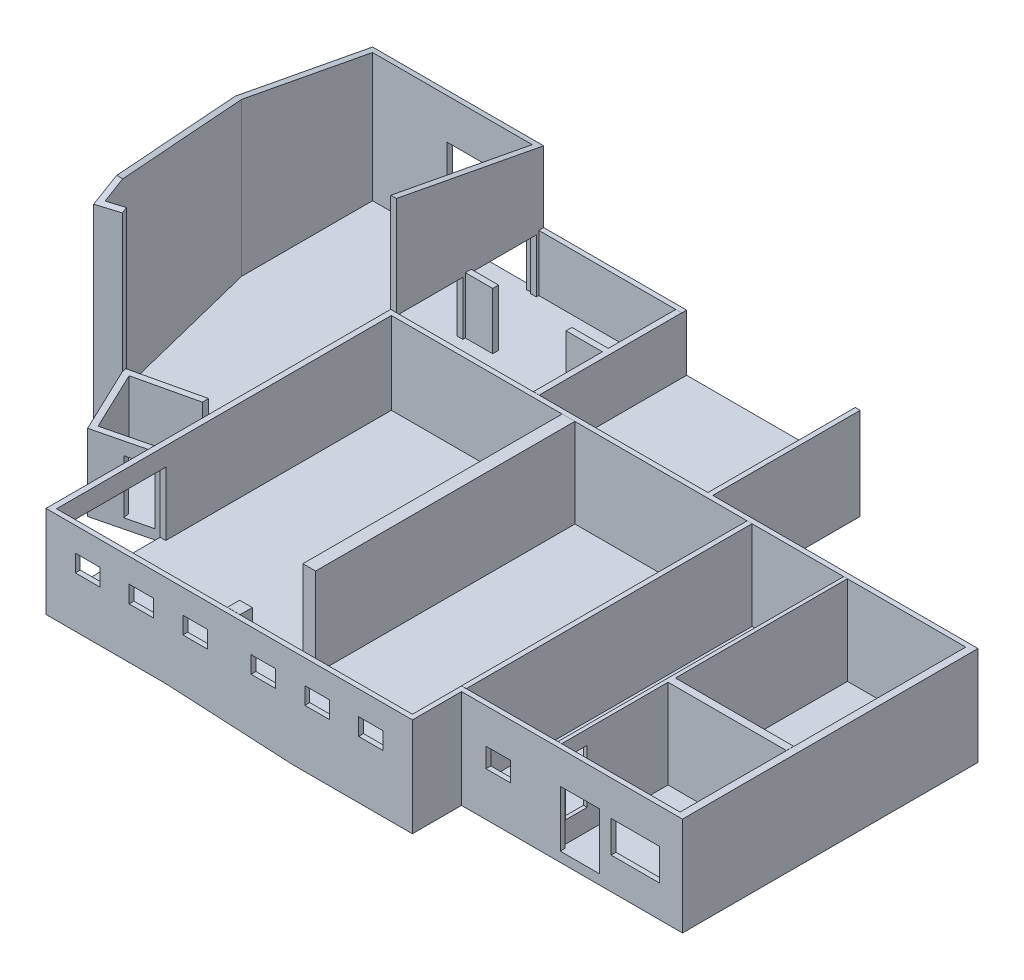
from build123d import *

# Parameters (mm, degrees)
AUFSATZ_LINEAR_AUSTRAGEN4_DEPTH                = 250
SKIZZE5_W                                      = 12750
SKIZZE5_H                                      = 5830
AUFSATZ_LINEAR_AUSTRAGEN5_DEPTH                = 3635
SKIZZE6_W                                      = 200
SKIZZE6_H                                      = 11690
SKIZZE6_W_2                                    = 520
SKIZZE6_H_2                                    = 10610
SKIZZE6_H_3                                    = 500
SKIZZE6_W_3                                    = 1120
SKIZZE6_H_4                                    = 240
AUFSATZ_LINEAR_AUSTRAGEN6_DEPTH                = 3640
SCHNITT_LINEAR_AUSTRAGEN1_REACH                = 30348.456
SKIZZE7_W                                      = 1980
SKIZZE7_H                                      = 1300
SKIZZE7_W_2                                    = 1600
SKIZZE7_H_2                                    = 2300
SKIZZE7_W_3                                    = 1000
SKIZZE7_H_3                                    = 800
SCHNITT_LINEAR_AUSTRAGEN2_REACH                = 27879.968
SKIZZE8_W                                      = 890
SKIZZE8_H                                      = 2200
SCHNITT_LINEAR_AUSTRAGEN3_REACH                = 31589.813
SKIZZE9_W                                      = 3870
SKIZZE9_H                                      = 2600
SKIZZE9_W_2                                    = 2565
SKIZZE9_H_2                                    = 2200
AUFSATZ_LINEAR_AUSTRAGEN7_DEPTH                = 3000
SKIZZE11_W                                     = 6990
SKIZZE11_H                                     = 13700
AUFSATZ_LINEAR_AUSTRAGEN8_DEPTH                = 275
SKIZZE12_W                                     = 12750
SKIZZE12_H                                     = 5830
AUFSATZ_LINEAR_AUSTRAGEN9_DEPTH                = 1325
AUFSATZ_LINEAR_AUSTRAGEN10_REACH               = 31462.736
SCHNITT_LINEAR_AUSTRAGEN4_DEPTH                = 3090
AUFSATZ_LINEAR_AUSTRAGEN12_DEPTH               = 8000
AUFSATZ_LINEAR_AUSTRAGEN13_DEPTH               = 1575
SCHNITT_LINEAR_AUSTRAGEN8_DEPTH                = 37827.06409607
SCHNITT_LINEAR_AUSTRAGEN8_DEPTH_BACK           = 37827.06409607
AUFSATZ_LINEAR_AUSTRAGEN14_REACH               = 31776.265
SKIZZE21_W                                     = 230
SKIZZE21_H                                     = 6030
SCHNITT_LINEAR_AUSTRAGEN9_DEPTH                = 1200
SCHNITT_LINEAR_AUSTRAGEN10_DEPTH               = 1050
SKIZZE24_W                                     = 1040
SKIZZE24_H                                     = 2200
SCHNITT_LINEAR_AUSTRAGEN11_DEPTH               = 300
SCHNITT_LINEAR_AUSTRAGEN12_REACH               = 32636.812
SKIZZE25_W                                     = 1000
SKIZZE25_H                                     = 700
SCHNITT_LINEAR_AUSTRAGEN13_REACH               = 32513.828
SKIZZE26_W                                     = 6900
SKIZZE26_H                                     = 3817.744695197
SCHNITT_LINEAR_AUSTRAGEN14_REACH               = 32489.323
SKIZZE27_W                                     = 3250
SKIZZE27_H                                     = 3600
AUFSATZ_LINEAR_AUSTRAGEN15_DEPTH               = 150
SCHNITT_LINEAR_AUSTRAGEN15_DEPTH               = 275
SCHNITT_LINEAR_AUSTRAGEN16_DEPTH               = 1050
SCHNITT_LINEAR_AUSTRAGEN17_REACH               = 33078.845
SCHNITT_LINEAR_AUSTRAGEN17_OFFSET_FROM_SURFACE = 400
SKIZZE31_W                                     = 5235
SKIZZE31_H                                     = 3290
SCHNITT_LINEAR_AUSTRAGEN18_DEPTH               = 1515


with BuildPart() as part:
    # Skizze1 → Aufsatz-Linear austragen4 (new body)
    with BuildSketch(Plane(origin=(0, 0, 0), x_dir=(1, 0, 0), z_dir=(0, 1, 0))):
        Polygon((14990, -18120), (14990, -20130), (0, -20130), (0, 0), (13180, 0), (13180, -6030), (24030, -6030), (24030, -18120), align=None)
    extrude(amount=AUFSATZ_LINEAR_AUSTRAGEN4_DEPTH)

    # Skizze5 → Aufsatz-Linear austragen5 (add)
    with BuildSketch(Plane(origin=(0, 250, 0), x_dir=(1, 0, 0), z_dir=(0, 1, 0))):
        Polygon((0, -20130), (14990, -20130), (14990, -18120), (24030, -18120), (24030, -6030), (13180, -6030), (13180, 0), (0, 0), align=None)
        Polygon((23730, -6230), (23730, -17920), (14790, -17920), (14790, -19930), (230, -19930), (230, -6230), align=None, mode=Mode.SUBTRACT)
        with Locations((6605, -3115)):
            Rectangle(SKIZZE5_W, SKIZZE5_H, mode=Mode.SUBTRACT)
    extrude(amount=AUFSATZ_LINEAR_AUSTRAGEN5_DEPTH)

    # Skizze6 → Aufsatz-Linear austragen6 (add)
    with BuildSketch(Plane(origin=(0, 250, 0), x_dir=(1, 0, 0), z_dir=(0, 1, 0))):
        Polygon((18890, -17920), (18890, -13570), (23730, -13570), (23730, -13270), (18890, -13270), (18890, -6230), (18740, -6230), (18740, -17920), align=None)
        with Locations((14890, -12075)):
            Rectangle(SKIZZE6_W, SKIZZE6_H)
        Polygon((5840, -200), (6080, -200), (6080, -6030), (5840, -6030), (5840, -3205), (4350, -3205), (4350, -2965), (5840, -2965), align=None)
        with Locations((7480, -11535)):
            Rectangle(SKIZZE6_W_2, SKIZZE6_H_2)
        with Locations((7480, -19680)):
            Rectangle(SKIZZE6_W_2, SKIZZE6_H_3)
        with Locations((790, -3085)):
            Rectangle(SKIZZE6_W_3, SKIZZE6_H_4)
    extrude(amount=AUFSATZ_LINEAR_AUSTRAGEN6_DEPTH)

    # Skizze7 → Schnitt-Linear austragen1 (cut, up to next)
    with BuildSketch(Plane.XY.offset(18120), mode=Mode.PRIVATE) as schnitt_linear_austragen1_sk1:
        with Locations((22100, 1800)):
            Rectangle(SKIZZE7_W, SKIZZE7_H)
    schnitt_linear_austragen1_tool1 = extrude(schnitt_linear_austragen1_sk1.sketch, amount=-SCHNITT_LINEAR_AUSTRAGEN1_REACH, mode=Mode.PRIVATE) & part.part
    # Skizze7 → Schnitt-Linear austragen1 (cut, up to next)
    with BuildSketch(Plane.XY.offset(18120), mode=Mode.PRIVATE) as schnitt_linear_austragen1_sk2:
        with Locations((19830, 1400)):
            Rectangle(SKIZZE7_W_2, SKIZZE7_H_2)
    schnitt_linear_austragen1_tool2 = extrude(schnitt_linear_austragen1_sk2.sketch, amount=-SCHNITT_LINEAR_AUSTRAGEN1_REACH, mode=Mode.PRIVATE) & part.part
    # Skizze7 → Schnitt-Linear austragen1 (cut, up to next)
    with BuildSketch(Plane.XY.offset(18120), mode=Mode.PRIVATE) as schnitt_linear_austragen1_sk3:
        with Locations((16490, 2050)):
            Rectangle(SKIZZE7_W_3, SKIZZE7_H_3)
    schnitt_linear_austragen1_tool3 = extrude(schnitt_linear_austragen1_sk3.sketch, amount=-SCHNITT_LINEAR_AUSTRAGEN1_REACH, mode=Mode.PRIVATE) & part.part
    add(schnitt_linear_austragen1_tool1.solids().sort_by_distance((22100, 1800, 18120))[0], mode=Mode.SUBTRACT)
    add(schnitt_linear_austragen1_tool2.solids().sort_by_distance((19830, 1400, 18120))[0], mode=Mode.SUBTRACT)
    add(schnitt_linear_austragen1_tool3.solids().sort_by_distance((16490, 2050, 18120))[0], mode=Mode.SUBTRACT)

    # Skizze8 → Schnitt-Linear austragen2 (cut, up to next)
    with BuildSketch(Plane(origin=(18890, 0, 0), x_dir=(0, 0, -1), z_dir=(1, 0, 0)), mode=Mode.PRIVATE) as schnitt_linear_austragen2_sk1:
        with Locations((-17325, 2210)):
            Rectangle(SKIZZE8_W, SKIZZE8_H)
    schnitt_linear_austragen2_tool1 = extrude(schnitt_linear_austragen2_sk1.sketch, amount=-SCHNITT_LINEAR_AUSTRAGEN2_REACH, mode=Mode.PRIVATE) & part.part
    add(schnitt_linear_austragen2_tool1.solids().sort_by_distance((18890, 2210, 17325))[0], mode=Mode.SUBTRACT)

    # Skizze9 → Schnitt-Linear austragen3 (cut, up to next)
    with BuildSketch(Plane.ZY, mode=Mode.PRIVATE) as schnitt_linear_austragen3_sk1:
        with Locations((17395, 1825)):
            Rectangle(SKIZZE9_W, SKIZZE9_H)
    schnitt_linear_austragen3_tool1 = extrude(schnitt_linear_austragen3_sk1.sketch, amount=-SCHNITT_LINEAR_AUSTRAGEN3_REACH, mode=Mode.PRIVATE) & part.part
    # Skizze9 → Schnitt-Linear austragen3 (cut, up to next)
    with BuildSketch(Plane.ZY, mode=Mode.PRIVATE) as schnitt_linear_austragen3_sk2:
        with Locations((1582.5, 2675)):
            Rectangle(SKIZZE9_W_2, SKIZZE9_H_2)
    schnitt_linear_austragen3_tool2 = extrude(schnitt_linear_austragen3_sk2.sketch, amount=-SCHNITT_LINEAR_AUSTRAGEN3_REACH, mode=Mode.PRIVATE) & part.part
    # Skizze9 → Schnitt-Linear austragen3 (cut, up to next)
    with BuildSketch(Plane.ZY, mode=Mode.PRIVATE) as schnitt_linear_austragen3_sk3:
        with Locations((4587.5, 2675)):
            Rectangle(SKIZZE9_W_2, SKIZZE9_H_2)
    schnitt_linear_austragen3_tool3 = extrude(schnitt_linear_austragen3_sk3.sketch, amount=-SCHNITT_LINEAR_AUSTRAGEN3_REACH, mode=Mode.PRIVATE) & part.part
    add(schnitt_linear_austragen3_tool1.solids().sort_by_distance((0, 1825, 17395))[0], mode=Mode.SUBTRACT)
    add(schnitt_linear_austragen3_tool2.solids().sort_by_distance((0, 2675, 1582.5))[0], mode=Mode.SUBTRACT)
    add(schnitt_linear_austragen3_tool3.solids().sort_by_distance((0, 2675, 4587.5))[0], mode=Mode.SUBTRACT)

    # Skizze10 → Aufsatz-Linear austragen7 (add)
    with BuildSketch(Plane(origin=(0, 250, 0), x_dir=(1, 0, 0), z_dir=(0, 1, 0))):
        Polygon((0, -14902.502697154), (0, -15160), (-2621.386680711, -15806.785799313), (-3994.91726562, -12922.29932281), (0, -12000), (0, -12256.576026948), (-3635.371342731, -13095.867632914), (-2483.325679823, -15515.224123031), align=None)
    extrude(amount=AUFSATZ_LINEAR_AUSTRAGEN7_DEPTH)

    # Skizze11 → Aufsatz-Linear austragen8 (add)
    with BuildSketch(Plane(origin=(0, 250, 0), x_dir=(1, 0, 0), z_dir=(0, 1, 0))):
        with Locations((3725, -13080)):
            Rectangle(SKIZZE11_W, SKIZZE11_H)
    extrude(amount=AUFSATZ_LINEAR_AUSTRAGEN8_DEPTH)

    # Skizze12 → Aufsatz-Linear austragen9 (add)
    with BuildSketch(Plane(origin=(0, 250, 0), x_dir=(1, 0, 0), z_dir=(0, 1, 0))):
        with Locations((6605, -3115)):
            Rectangle(SKIZZE12_W, SKIZZE12_H)
    extrude(amount=AUFSATZ_LINEAR_AUSTRAGEN9_DEPTH)

    # Aufsatz-Linear austragen10: up to this face of the body (flat: up to its plane)
    aufsatz_linear_austragen10_end = Plane(part.part.faces().sort_by_distance((7480, 2070, 16840))[0])
    # Skizze13 → Aufsatz-Linear austragen10 (add, up to the picked face)
    with BuildSketch(Plane(origin=(0, 0, 19930), x_dir=(-1, 0, 0), z_dir=(0, 0, -1)), mode=Mode.PRIVATE) as aufsatz_linear_austragen10_sk1:
        Polygon((-4895, 525), (-10130, 250), (-4895, 250), align=None)
    aufsatz_linear_austragen10_tool1 = split(extrude(aufsatz_linear_austragen10_sk1.sketch, amount=AUFSATZ_LINEAR_AUSTRAGEN10_REACH, mode=Mode.PRIVATE), bisect_by=aufsatz_linear_austragen10_end, keep=Keep.BOTH, mode=Mode.PRIVATE)
    add(aufsatz_linear_austragen10_tool1.solids().sort_by(Axis((6640, 341.666667, 19930), (0, 0, -1)))[0])

    # Skizze14 → Schnitt-Linear austragen4 (cut)
    with BuildSketch(Plane(origin=(0, 0, 19930), x_dir=(-1, 0, 0), z_dir=(0, 0, -1))):
        Polygon((-4895, 525), (-7220, 525), (-7220, 402.865329513), align=None)
    extrude(amount=SCHNITT_LINEAR_AUSTRAGEN4_DEPTH, mode=Mode.SUBTRACT)

    # Skizze18 → Aufsatz-Linear austragen12 (add)
    with BuildSketch(Plane(origin=(0, 1575, 0), x_dir=(1, 0, 0), z_dir=(0, 1, 0))):
        Polygon((0, 0), (-6770, 0), (-6770, -5625), (-4848.656305147, -13331.088658084), (-3911.521546198, -13097.43472024), (-3969.582801141, -12864.563745934), (-4673.846585785, -13040.156428834), (-6530, -5595.531705383), (-6530, -240), (0, -240), align=None)
    extrude(amount=AUFSATZ_LINEAR_AUSTRAGEN12_DEPTH)

    # Skizze19 → Aufsatz-Linear austragen13 (add)
    with BuildSketch(Plane.XZ.offset(-1575)):
        Polygon((-2621.386680711, 15806.785799313), (0, 15160), (0, 0), (-6770, 0), (-6770, 5625), (-4848.656305147, 13331.088658084), (-3911.521546198, 13097.43472024), align=None)
    extrude(amount=AUFSATZ_LINEAR_AUSTRAGEN13_DEPTH)

    # Skizze20 → Schnitt-Linear austragen8 (cut, two sides)
    with BuildSketch(Plane.ZY.offset(-23790)) as schnitt_linear_austragen8_sk:
        Polygon((12075.002540109, 9075.964650046), (-1187.358000417, 6556.146433623), (-1198.809144532, 13266.908889698), (21923.923844096, 13266.908889698), (21923.923844096, 7205.71067909), align=None)
    extrude(amount=SCHNITT_LINEAR_AUSTRAGEN8_DEPTH, mode=Mode.SUBTRACT)
    extrude(schnitt_linear_austragen8_sk.sketch, amount=-SCHNITT_LINEAR_AUSTRAGEN8_DEPTH_BACK, mode=Mode.SUBTRACT)

    # Aufsatz-Linear austragen14: up to this plane
    aufsatz_linear_austragen14_end = Plane(origin=(24030, 9075.964650046, 12075.002540109), z_dir=(0, -0.982424863110441, 0.18665848049963168))
    # Skizze21 → Aufsatz-Linear austragen14 (add, up to the surface)
    with BuildSketch(Plane(origin=(0, 3885, 0), x_dir=(1, 0, 0), z_dir=(0, 1, 0)), mode=Mode.PRIVATE) as aufsatz_linear_austragen14_sk1:
        with Locations((115, -3015)):
            Rectangle(SKIZZE21_W, SKIZZE21_H)
    aufsatz_linear_austragen14_tool1 = split(extrude(aufsatz_linear_austragen14_sk1.sketch, amount=AUFSATZ_LINEAR_AUSTRAGEN14_REACH, mode=Mode.PRIVATE), bisect_by=aufsatz_linear_austragen14_end, keep=Keep.BOTH, mode=Mode.PRIVATE)
    add(aufsatz_linear_austragen14_tool1.solids().sort_by_distance((115, 3885, 3015))[0])

    # Skizze22 → Schnitt-Linear austragen9 (cut)
    with BuildSketch(Plane.ZY.offset(1200)):
        Polygon((9555.409574458, 1575), (9815.409574458, 1575), (9815.409574458, 1395), (10075.409574458, 1395), (10075.409574458, 1215), (10335.409574458, 1215), (10335.409574458, 1035), (10595.409574458, 1035), (10595.409574458, 855), (10855.409574458, 855), (10855.409574458, 675), (13323.160508591, 675), (13323.160508591, 5461.397070598), (9555.409574458, 5461.397070598), align=None)
    extrude(amount=-SCHNITT_LINEAR_AUSTRAGEN9_DEPTH, mode=Mode.SUBTRACT)

    # Skizze23 → Schnitt-Linear austragen10 (cut)
    with BuildSketch(Plane(origin=(0, 1575, 0), x_dir=(1, 0, 0), z_dir=(0, 1, 0))):
        Polygon((-1200, -13323.160508591), (-1200, -12533.617856299), (-3635.371342731, -13095.867632914), (-2483.325679823, -15515.224123031), (0, -14902.502697154), (0, -13323.160508591), align=None)
    extrude(amount=-SCHNITT_LINEAR_AUSTRAGEN10_DEPTH, mode=Mode.SUBTRACT)

    # Skizze24 → Schnitt-Linear austragen11 (cut)
    with BuildSketch(Plane(origin=(3525.845171827, 0, 14290.0533399), x_dir=(0.9708839558187317, 0, -0.23955029604191938), z_dir=(0.23955029604191938, 0, 0.9708839558187317))):
        with Locations((-4581.582487995, 1625)):
            Rectangle(SKIZZE24_W, SKIZZE24_H)
    extrude(amount=-SCHNITT_LINEAR_AUSTRAGEN11_DEPTH, mode=Mode.SUBTRACT)

    # Skizze25 → Schnitt-Linear austragen12 (cut, up to next)
    with BuildSketch(Plane.XY.offset(20130), mode=Mode.PRIVATE) as schnitt_linear_austragen12_sk1:
        with Locations((1700, 2550)):
            Rectangle(SKIZZE25_W, SKIZZE25_H)
    schnitt_linear_austragen12_tool1 = extrude(schnitt_linear_austragen12_sk1.sketch, amount=-SCHNITT_LINEAR_AUSTRAGEN12_REACH, mode=Mode.PRIVATE) & part.part
    # Skizze25 → Schnitt-Linear austragen12 (cut, up to next)
    with BuildSketch(Plane.XY.offset(20130), mode=Mode.PRIVATE) as schnitt_linear_austragen12_sk2:
        with Locations((3900, 2550)):
            Rectangle(SKIZZE25_W, SKIZZE25_H)
    schnitt_linear_austragen12_tool2 = extrude(schnitt_linear_austragen12_sk2.sketch, amount=-SCHNITT_LINEAR_AUSTRAGEN12_REACH, mode=Mode.PRIVATE) & part.part
    # Skizze25 → Schnitt-Linear austragen12 (cut, up to next)
    with BuildSketch(Plane.XY.offset(20130), mode=Mode.PRIVATE) as schnitt_linear_austragen12_sk3:
        with Locations((6100, 2550)):
            Rectangle(SKIZZE25_W, SKIZZE25_H)
    schnitt_linear_austragen12_tool3 = extrude(schnitt_linear_austragen12_sk3.sketch, amount=-SCHNITT_LINEAR_AUSTRAGEN12_REACH, mode=Mode.PRIVATE) & part.part
    # Skizze25 → Schnitt-Linear austragen12 (cut, up to next)
    with BuildSketch(Plane.XY.offset(20130), mode=Mode.PRIVATE) as schnitt_linear_austragen12_sk4:
        with Locations((8890, 2550)):
            Rectangle(SKIZZE25_W, SKIZZE25_H)
    schnitt_linear_austragen12_tool4 = extrude(schnitt_linear_austragen12_sk4.sketch, amount=-SCHNITT_LINEAR_AUSTRAGEN12_REACH, mode=Mode.PRIVATE) & part.part
    # Skizze25 → Schnitt-Linear austragen12 (cut, up to next)
    with BuildSketch(Plane.XY.offset(20130), mode=Mode.PRIVATE) as schnitt_linear_austragen12_sk5:
        with Locations((11090, 2550)):
            Rectangle(SKIZZE25_W, SKIZZE25_H)
    schnitt_linear_austragen12_tool5 = extrude(schnitt_linear_austragen12_sk5.sketch, amount=-SCHNITT_LINEAR_AUSTRAGEN12_REACH, mode=Mode.PRIVATE) & part.part
    # Skizze25 → Schnitt-Linear austragen12 (cut, up to next)
    with BuildSketch(Plane.XY.offset(20130), mode=Mode.PRIVATE) as schnitt_linear_austragen12_sk6:
        with Locations((13290, 2550)):
            Rectangle(SKIZZE25_W, SKIZZE25_H)
    schnitt_linear_austragen12_tool6 = extrude(schnitt_linear_austragen12_sk6.sketch, amount=-SCHNITT_LINEAR_AUSTRAGEN12_REACH, mode=Mode.PRIVATE) & part.part
    add(schnitt_linear_austragen12_tool1.solids().sort_by_distance((1700, 2550, 20130))[0], mode=Mode.SUBTRACT)
    add(schnitt_linear_austragen12_tool2.solids().sort_by_distance((3900, 2550, 20130))[0], mode=Mode.SUBTRACT)
    add(schnitt_linear_austragen12_tool3.solids().sort_by_distance((6100, 2550, 20130))[0], mode=Mode.SUBTRACT)
    add(schnitt_linear_austragen12_tool4.solids().sort_by_distance((8890, 2550, 20130))[0], mode=Mode.SUBTRACT)
    add(schnitt_linear_austragen12_tool5.solids().sort_by_distance((11090, 2550, 20130))[0], mode=Mode.SUBTRACT)
    add(schnitt_linear_austragen12_tool6.solids().sort_by_distance((13290, 2550, 20130))[0], mode=Mode.SUBTRACT)

    # Skizze26 → Schnitt-Linear austragen13 (cut, up to next)
    with BuildSketch(Plane.XY.offset(200), mode=Mode.PRIVATE) as schnitt_linear_austragen13_sk1:
        with Locations((9530, 3483.872347599)):
            Rectangle(SKIZZE26_W, SKIZZE26_H)
    schnitt_linear_austragen13_tool1 = extrude(schnitt_linear_austragen13_sk1.sketch, amount=-SCHNITT_LINEAR_AUSTRAGEN13_REACH, mode=Mode.PRIVATE) & part.part
    add(schnitt_linear_austragen13_tool1.solids().sort_by_distance((9530, 3483.872348, 200))[0], mode=Mode.SUBTRACT)

    # Skizze27 → Schnitt-Linear austragen14 (cut, up to next)
    with BuildSketch(Plane.XY.offset(240), mode=Mode.PRIVATE) as schnitt_linear_austragen14_sk1:
        with Locations((-1865, 3375)):
            Rectangle(SKIZZE27_W, SKIZZE27_H)
    schnitt_linear_austragen14_tool1 = extrude(schnitt_linear_austragen14_sk1.sketch, amount=-SCHNITT_LINEAR_AUSTRAGEN14_REACH, mode=Mode.PRIVATE) & part.part
    add(schnitt_linear_austragen14_tool1.solids().sort_by_distance((-1865, 3375, 240))[0], mode=Mode.SUBTRACT)

    # Skizze28 → Aufsatz-Linear austragen15 (add)
    with BuildSketch(Plane.XZ):
        Polygon((24030, 18120), (14990, 18120), (14990, 20130), (0, 20130), (0, 15160), (-2621.386680711, 15806.785799313), (-3911.521546198, 13097.43472024), (-4848.656305147, 13331.088658084), (-6770, 5625), (-6770, 0), (13180, 0), (13180, 6030), (24030, 6030), align=None)
    extrude(amount=AUFSATZ_LINEAR_AUSTRAGEN15_DEPTH)

    # Skizze29 → Schnitt-Linear austragen15 (cut)
    with BuildSketch(Plane.XZ.offset(150)):
        Polygon((13180, 0), (13180, 6130), (7480, 6130), (7480, 16840), (4895, 16840), (4895, 20130), (0, 20130), (0, 15160), (-2621.386680711, 15806.785799313), (-3911.521546198, 13097.43472024), (-4848.656305147, 13331.088658084), (-6770, 5625), (-6770, 0), align=None)
    extrude(amount=-SCHNITT_LINEAR_AUSTRAGEN15_DEPTH, mode=Mode.SUBTRACT)

    # Skizze30 → Schnitt-Linear austragen16 (cut)
    with BuildSketch(Plane.XZ.offset(-125)):
        Polygon((-6770, 0), (115, 0), (115, 9815.409574458), (-1400, 9815.409574458), (-1400, 12451.50348105), (-3815.144304175, 13009.083477862), (-3911.521546198, 13097.43472024), (-4848.656305147, 13331.088658084), (-6770, 5625), align=None)
    extrude(amount=-SCHNITT_LINEAR_AUSTRAGEN16_DEPTH, mode=Mode.SUBTRACT)

    # Schnitt-Linear austragen17: up to this face of the body (flat: up to its plane, moved by the offset)
    schnitt_linear_austragen17_end = Plane(part.part.faces().sort_by_distance((7513.030907286, 387.472110888, 18363.845386604))[0]).offset(-SCHNITT_LINEAR_AUSTRAGEN17_OFFSET_FROM_SURFACE)
    # Skizze31 → Schnitt-Linear austragen17 (cut, up to the picked face)
    with BuildSketch(Plane.XZ.offset(150), mode=Mode.PRIVATE) as schnitt_linear_austragen17_sk1:
        with Locations((7512.5, 18485)):
            Rectangle(SKIZZE31_W, SKIZZE31_H)
    schnitt_linear_austragen17_tool1 = split(extrude(schnitt_linear_austragen17_sk1.sketch, amount=-SCHNITT_LINEAR_AUSTRAGEN17_REACH, mode=Mode.PRIVATE), bisect_by=schnitt_linear_austragen17_end, keep=Keep.BOTH, mode=Mode.PRIVATE)
    add(schnitt_linear_austragen17_tool1.solids().sort_by(Axis((7512.5, -150, 18485), (0, 1, 0)))[0], mode=Mode.SUBTRACT)

    # Skizze32 → Schnitt-Linear austragen18 (cut)
    with BuildSketch(Plane.ZY.offset(1400)):
        Polygon((10455.409574458, 275), (12451.50348105, 275), (12451.50348105, 125), (9415.409574458, 125), (9415.409574458, 995), (9675.409574458, 995), (9675.409574458, 815), (9935.409574458, 815), (9935.409574458, 635), (10195.409574458, 635), (10195.409574458, 455), (10455.409574458, 455), align=None)
    extrude(amount=-SCHNITT_LINEAR_AUSTRAGEN18_DEPTH, mode=Mode.SUBTRACT)


solid = part.part
